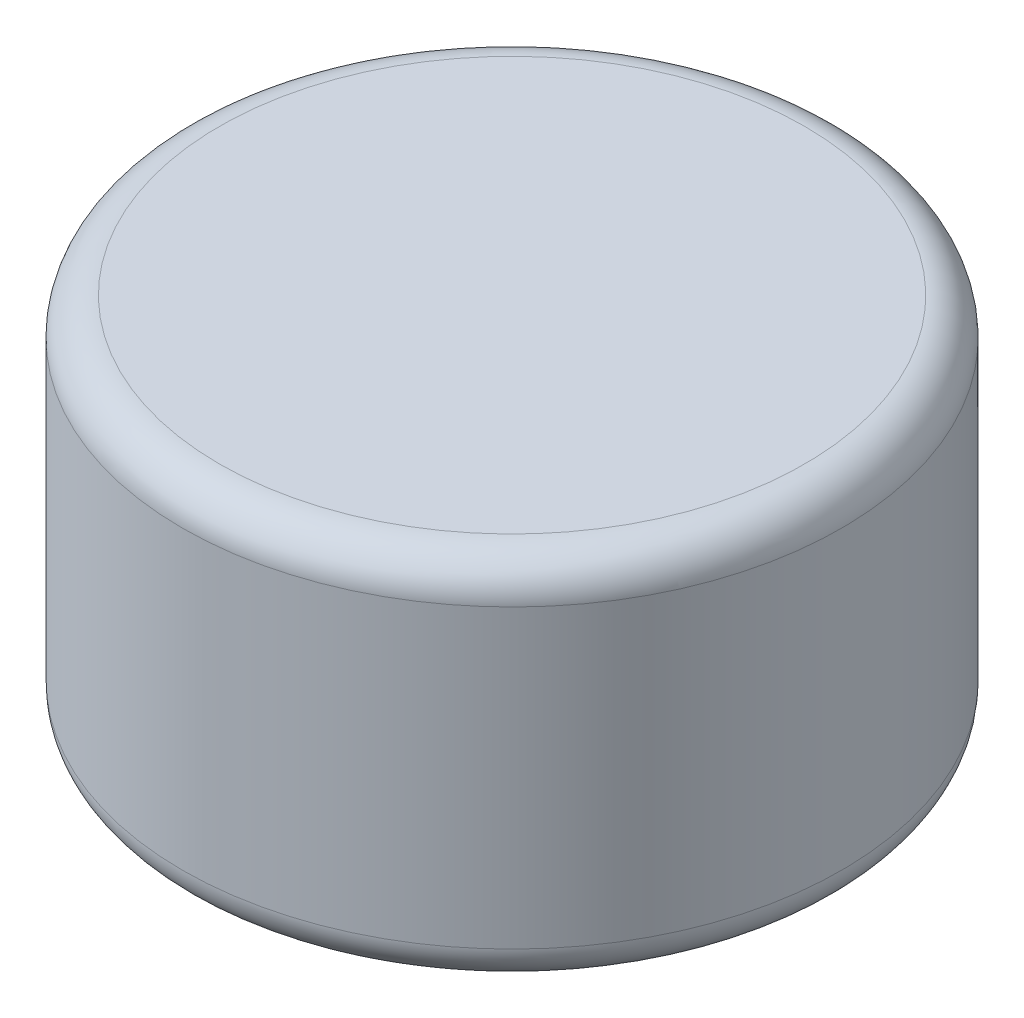
from build123d import *

# Parameters (mm, degrees)
SKETCH_1_R          = 44.5
EXTRUDE_1_DEPTH     = 25
FILLET_1_R          = 5
SKETCH_9_R          = 40.5
CUT_EXTRUDE_1_DEPTH = 20.05


with BuildPart() as part:
    # 草图1 → 凸台-拉伸1 (new body, symmetric)
    with BuildSketch(Plane(origin=(0, 0, 0), x_dir=(1, 0, 0), z_dir=(0, 1, 0))):
        Circle(SKETCH_1_R)
    extrude(amount=EXTRUDE_1_DEPTH, both=True)

    # 圆角1
    fillet_1_edges = [part.edges().sort_by_distance(p)[0] for p in [
        (-44.5, -25, 0),
        (-44.5, 25, 0),
    ]]
    fillet(fillet_1_edges, radius=FILLET_1_R)

    # 草图9 → 切除-拉伸1 (cut, symmetric)
    with BuildSketch(Plane(origin=(0, 0, 0), x_dir=(1, 0, 0), z_dir=(0, 1, 0))):
        Circle(SKETCH_9_R)
    extrude(amount=CUT_EXTRUDE_1_DEPTH, both=True, mode=Mode.SUBTRACT)


solid = part.part
